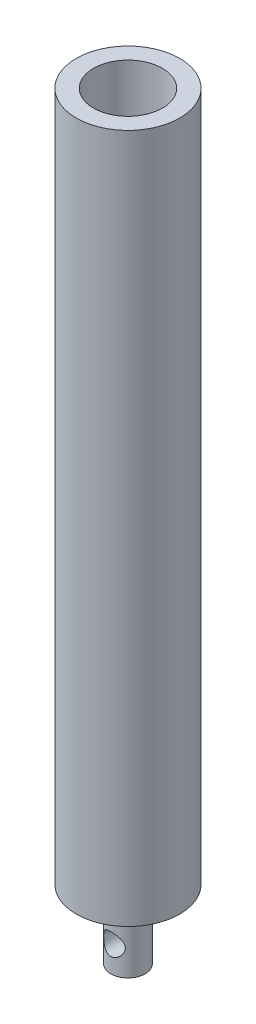
from build123d import *

# Parameters (mm, degrees)
SKETCH1_R               = 19.05
BOSS_EXTRUDE1_DEPTH     = 254
SKETCH1_3_R             = 6.35
BOSS_EXTRUDE2_DEPTH     = 25.4
SKETCH2_R               = 12.7
CUT_EXTRUDE1_DEPTH      = 203.2
CUT_EXTRUDE2_DEPTH      = 256.424754086
CUT_EXTRUDE2_DEPTH_BACK = 256.424754086
SKETCH3_R               = 3.96875


with BuildPart() as part:
    # Sketch1 → Boss-Extrude1 (new body)
    with BuildSketch(Plane(origin=(0, 0, 0), x_dir=(1, 0, 0), z_dir=(0, 1, 0))):
        Circle(SKETCH1_R)
    extrude(amount=BOSS_EXTRUDE1_DEPTH)

    # Sketch1_3 → Boss-Extrude2 (add)
    with BuildSketch(Plane(origin=(0, 0, 0), x_dir=(1, 0, 0), z_dir=(0, 1, 0))):
        Circle(SKETCH1_3_R)
    extrude(amount=-BOSS_EXTRUDE2_DEPTH)

    # Sketch2 → Cut-Extrude1 (cut)
    with BuildSketch(Plane(origin=(0, 254, 0), x_dir=(1, 0, 0), z_dir=(0, 1, 0))):
        Circle(SKETCH2_R)
    extrude(amount=-CUT_EXTRUDE1_DEPTH, mode=Mode.SUBTRACT)

    # Sketch3 → Cut-Extrude2 (cut, two sides: drawn at the far end of the back side and taken through both)
    with BuildSketch(Plane.XY.offset(-CUT_EXTRUDE2_DEPTH_BACK)):
        with Locations((0, -15.875)):
            Circle(SKETCH3_R)
    extrude(amount=CUT_EXTRUDE2_DEPTH + CUT_EXTRUDE2_DEPTH_BACK, mode=Mode.SUBTRACT)


solid = part.part
